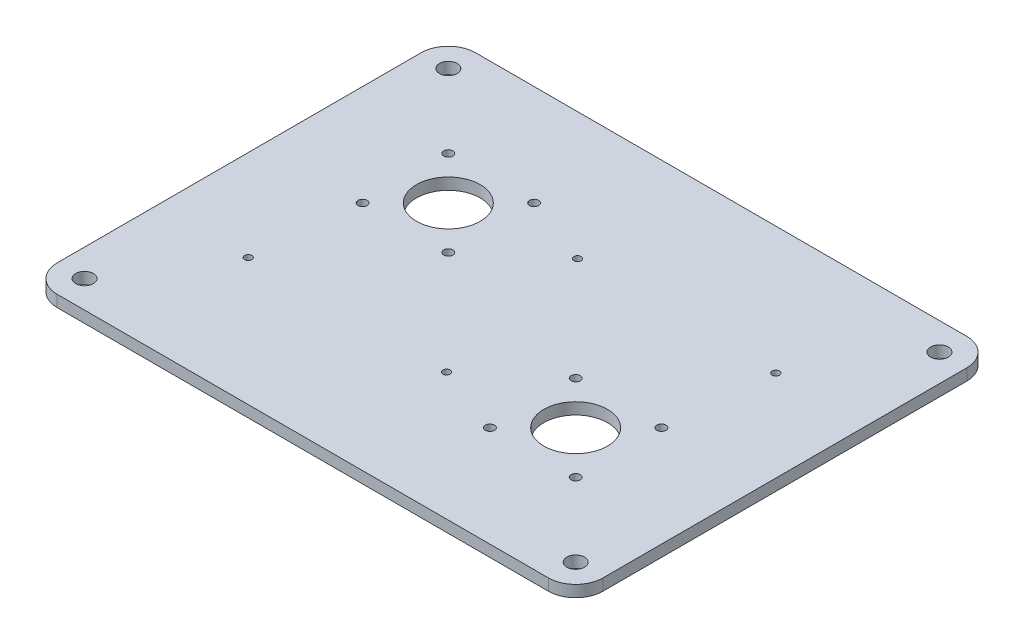
from build123d import *

# Parameters (mm, degrees)
SKETCH1_R           = 4.85
SKETCH1_R_2         = 2.5
SKETCH1_R_3         = 17.5
BOSS_EXTRUDE1_DEPTH = 6.35
SKETCH5_R           = 2
CUT_EXTRUDE2_DEPTH  = 10


with BuildPart() as part:
    # Sketch1 → Boss-Extrude1 (new body)
    with BuildSketch(Plane(origin=(0, 0, 0), x_dir=(1, 0, 0), z_dir=(0, 1, 0))):
        with BuildLine():
            Line((-132.651439051, 165.421561199), (137.348560949, 165.421561199))
            ThreePointArc((137.348560949, 165.421561199), (147.955162667, 161.028162917), (152.348560949, 150.421561199))
            Line((152.348560949, 150.421561199), (152.348560949, -49.578438801))
            ThreePointArc((152.348560949, -49.578438801), (147.955162667, -60.185040519), (137.348560949, -64.578438801))
            Line((137.348560949, -64.578438801), (-132.651439051, -64.578438801))
            ThreePointArc((-132.651439051, -64.578438801), (-143.258040769, -60.185040519), (-147.651439051, -49.578438801))
            Line((-147.651439051, -49.578438801), (-147.651439051, 150.421561199))
            ThreePointArc((-147.651439051, 150.421561199), (-143.258040769, 161.028162917), (-132.651439051, 165.421561199))
        make_face()
        with Locations((-132.651439051, 150.421561199)):
            Circle(SKETCH1_R, mode=Mode.SUBTRACT)
        with Locations((137.348560949, -49.578438801)):
            Circle(SKETCH1_R, mode=Mode.SUBTRACT)
        with Locations((-45.081439051, 109.991561199)):
            Circle(SKETCH1_R_2, mode=Mode.SUBTRACT)
        with Locations((-45.081439051, 62.851561199)):
            Circle(SKETCH1_R_2, mode=Mode.SUBTRACT)
        with Locations((-92.221439051, 62.851561199)):
            Circle(SKETCH1_R_2, mode=Mode.SUBTRACT)
        with Locations((-92.221439051, 109.991561199)):
            Circle(SKETCH1_R_2, mode=Mode.SUBTRACT)
        with Locations((49.778560949, 37.991561199)):
            Circle(SKETCH1_R_2, mode=Mode.SUBTRACT)
        with Locations((96.918560949, 37.991561199)):
            Circle(SKETCH1_R_2, mode=Mode.SUBTRACT)
        with Locations((96.918560949, -9.148438801)):
            Circle(SKETCH1_R_2, mode=Mode.SUBTRACT)
        with Locations((49.778560949, -9.148438801)):
            Circle(SKETCH1_R_2, mode=Mode.SUBTRACT)
        with Locations((137.348560949, 150.421561199)):
            Circle(SKETCH1_R, mode=Mode.SUBTRACT)
        with Locations((-132.651439051, -49.578438801)):
            Circle(SKETCH1_R, mode=Mode.SUBTRACT)
        with Locations((-68.651439051, 86.421561199)):
            Circle(SKETCH1_R_3, mode=Mode.SUBTRACT)
        with Locations((73.348560949, 14.421561199)):
            Circle(SKETCH1_R_3, mode=Mode.SUBTRACT)
    extrude(amount=BOSS_EXTRUDE1_DEPTH)

    # Sketch5 → Cut-Extrude2 (cut)
    with BuildSketch(Plane.XZ):
        with Locations((-97.651439051, -5.421561199)):
            Circle(SKETCH5_R)
        with Locations((11.348560949, -5.421561199)):
            Circle(SKETCH5_R)
        with Locations((-6.651439051, -95.421561199)):
            Circle(SKETCH5_R)
        with Locations((102.348560949, -95.421561199)):
            Circle(SKETCH5_R)
    extrude(amount=-CUT_EXTRUDE2_DEPTH, mode=Mode.SUBTRACT)


solid = part.part
